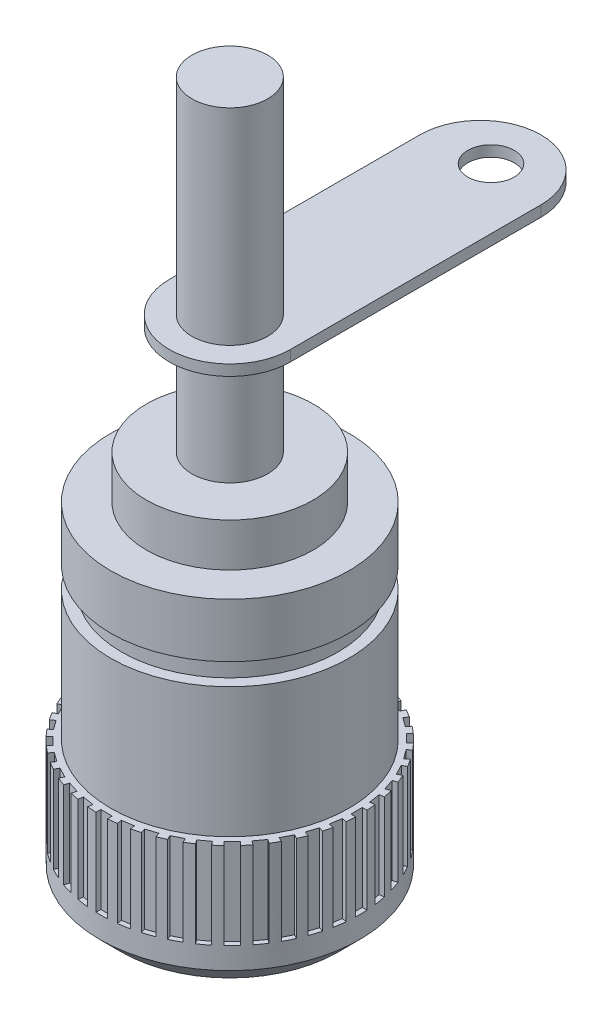
from build123d import *

# Parameters (mm, degrees)
SKETCH1_R           = 6
BOSS_EXTRUDE1_DEPTH = 12
SKETCH2_R           = 8.118200381
SKETCH2_R_2         = 5.5
CUT_EXTRUDE1_DEPTH  = 6
CHAMFER1_SIZE       = 1
SKETCH3_R           = 3.25
CUT_EXTRUDE2_DEPTH  = 6
SKETCH5_R           = 5
BOSS_EXTRUDE2_DEPTH = 1
SKETCH6_R           = 5.5
BOSS_EXTRUDE3_DEPTH = 2.5
SKETCH7_R           = 2.716529656
SKETCH7_R_2         = 2.485668045
BOSS_EXTRUDE4_DEPTH = 4.5
SKETCH8_R           = 3.85
BOSS_EXTRUDE5_DEPTH = 2
SKETCH9_R           = 1.75
BOSS_EXTRUDE6_DEPTH = 15
BOSS_EXTRUDE7_START = 5
BOSS_EXTRUDE7_DEPTH = 0.5
SKETCH11_R          = 1.071169835
CUT_EXTRUDE3_DEPTH  = 0.5
CUT_EXTRUDE4_START  = -2
SKETCH12_W          = 0.527806269
SKETCH12_H          = 0.650551913
SKETCH12_W_2        = 0.650551913
SKETCH12_H_2        = 0.527806269
CUT_EXTRUDE4_DEPTH  = 8.5


with BuildPart() as part:
    # Sketch1 → Boss-Extrude1 (new body)
    with BuildSketch(Plane(origin=(0, 0, 0), x_dir=(1, 0, 0), z_dir=(0, 1, 0))):
        Circle(SKETCH1_R)
    extrude(amount=BOSS_EXTRUDE1_DEPTH)

    # Sketch2 → Cut-Extrude1 (cut)
    with BuildSketch(Plane(origin=(0, 12, 0), x_dir=(1, 0, 0), z_dir=(0, 1, 0))):
        Circle(SKETCH2_R)
        Circle(SKETCH2_R_2, mode=Mode.SUBTRACT)
    extrude(amount=-CUT_EXTRUDE1_DEPTH, mode=Mode.SUBTRACT)

    # Chamfer1
    chamfer1_edges = [part.edges().sort_by_distance(p)[0] for p in [
        (-6, 0, 0),
    ]]
    chamfer(chamfer1_edges, length=CHAMFER1_SIZE)

    # Sketch3 → Cut-Extrude2 (cut)
    with BuildSketch(Plane.XZ):
        Circle(SKETCH3_R)
    extrude(amount=-CUT_EXTRUDE2_DEPTH, mode=Mode.SUBTRACT)

    # Sketch5 → Boss-Extrude2 (add)
    with BuildSketch(Plane(origin=(0, 12, 0), x_dir=(1, 0, 0), z_dir=(0, 1, 0))):
        Circle(SKETCH5_R)
    extrude(amount=BOSS_EXTRUDE2_DEPTH)

    # Sketch6 → Boss-Extrude3 (add)
    with BuildSketch(Plane(origin=(0, 13, 0), x_dir=(1, 0, 0), z_dir=(0, 1, 0))):
        Circle(SKETCH6_R)
    extrude(amount=BOSS_EXTRUDE3_DEPTH)

    # Sketch7 → Boss-Extrude4 (add)
    with BuildSketch(Plane.XZ.offset(-6)):
        Circle(SKETCH7_R)
        Circle(SKETCH7_R_2, mode=Mode.SUBTRACT)
    extrude(amount=BOSS_EXTRUDE4_DEPTH)

    # Sketch8 → Boss-Extrude5 (add)
    with BuildSketch(Plane(origin=(0, 15.5, 0), x_dir=(1, 0, 0), z_dir=(0, 1, 0))):
        Circle(SKETCH8_R)
    extrude(amount=BOSS_EXTRUDE5_DEPTH)

    # Sketch9 → Boss-Extrude6 (add)
    with BuildSketch(Plane(origin=(0, 17.5, 0), x_dir=(1, 0, 0), z_dir=(0, 1, 0))):
        Circle(SKETCH9_R)
    extrude(amount=BOSS_EXTRUDE6_DEPTH)

    # Sketch10 → Boss-Extrude7 (add)
    with BuildSketch(Plane(origin=(0, 17.5, 0), x_dir=(1, 0, 0), z_dir=(0, 1, 0)).offset(BOSS_EXTRUDE7_START)):
        with BuildLine():
            Line((-2.797833614, 0), (-2.797833614, 11.571992089))
            ThreePointArc((-2.797833614, 11.571992089), (0, 14.369825702), (2.797833614, 11.571992089))
            Line((2.797833614, 11.571992089), (2.797833614, 0))
            ThreePointArc((2.797833614, 0), (0, -2.797833614), (-2.797833614, 0))
        make_face()
    extrude(amount=BOSS_EXTRUDE7_DEPTH)

    # Sketch11 → Cut-Extrude3 (cut)
    with BuildSketch(Plane.XZ.offset(-22.5)):
        with Locations((0, -12.0617981)):
            Circle(SKETCH11_R)
    extrude(amount=-CUT_EXTRUDE3_DEPTH, mode=Mode.SUBTRACT)

    # Sketch12 → Cut-Extrude4 (cut)
    with BuildSketch(Plane.XZ.offset(CUT_EXTRUDE4_START)):
        Polygon((0.824722278, 6.374190464), (0.722953537, 5.731647924), (1.244261635, 5.649080833), (1.346030376, 6.291623372), align=None)
        with Locations((0.081328638, 6.099452634)):
            Rectangle(SKETCH12_W, SKETCH12_H)
        Polygon((1.811711653, 6.166698614), (1.610680056, 5.547986977), (2.112653648, 5.38488587), (2.313685245, 6.003597507), align=None)
        Polygon((2.754090675, 5.807362177), (2.458746287, 5.227716178), (2.929025116, 4.988097146), (3.224369505, 5.567743145), align=None)
        Polygon((3.628654844, 5.305029211), (3.246270024, 4.778721657), (3.673274265, 4.468484916), (4.055659086, 4.994792469), align=None)
        Polygon((4.413869488, 4.672068819), (3.953859819, 4.212059149), (4.327075211, 3.838843757), (4.78708488, 4.298853426), align=None)
        Polygon((5.090400017, 3.924066586), (4.564092463, 3.541681766), (4.874329204, 3.114677524), (5.400636758, 3.497062345), align=None)
        Polygon((5.641588003, 3.079440812), (5.061942003, 2.784096423), (5.301561035, 2.313817594), (5.881207035, 2.609161982), align=None)
        Polygon((6.053861369, 2.158988984), (5.435149732, 1.957957387), (5.598250839, 1.455983795), (6.216962476, 1.657015392), align=None)
        Polygon((6.317068576, 1.185375682), (5.674526036, 1.083606942), (5.757093128, 0.562298843), (6.399635668, 0.664067584), align=None)
        with Locations((6.099452634, -0.081328638)):
            Rectangle(SKETCH12_W_2, SKETCH12_H_2)
        Polygon((6.374190464, -0.824722278), (5.731647924, -0.722953537), (5.649080833, -1.244261635), (6.291623372, -1.346030376), align=None)
        Polygon((6.166698614, -1.811711653), (5.547986977, -1.610680056), (5.38488587, -2.112653648), (6.003597507, -2.313685245), align=None)
        Polygon((5.807362177, -2.754090675), (5.227716178, -2.458746287), (4.988097146, -2.929025116), (5.567743145, -3.224369505), align=None)
        Polygon((5.305029211, -3.628654844), (4.778721657, -3.246270024), (4.468484916, -3.673274265), (4.994792469, -4.055659086), align=None)
        Polygon((4.672068819, -4.413869488), (4.212059149, -3.953859819), (3.838843757, -4.327075211), (4.298853426, -4.78708488), align=None)
        Polygon((3.924066586, -5.090400017), (3.541681766, -4.564092463), (3.114677524, -4.874329204), (3.497062345, -5.400636758), align=None)
        Polygon((3.079440812, -5.641588003), (2.784096423, -5.061942003), (2.313817594, -5.301561035), (2.609161982, -5.881207035), align=None)
        Polygon((2.158988984, -6.053861369), (1.957957387, -5.435149732), (1.455983795, -5.598250839), (1.657015392, -6.216962476), align=None)
        Polygon((1.185375682, -6.317068576), (1.083606942, -5.674526036), (0.562298843, -5.757093128), (0.664067584, -6.399635668), align=None)
        with Locations((-0.081328638, -6.099452634)):
            Rectangle(SKETCH12_W, SKETCH12_H)
        Polygon((-0.824722278, -6.374190464), (-0.722953537, -5.731647924), (-1.244261635, -5.649080833), (-1.346030376, -6.291623372), align=None)
        Polygon((-1.811711653, -6.166698614), (-1.610680056, -5.547986977), (-2.112653648, -5.38488587), (-2.313685245, -6.003597507), align=None)
        Polygon((-2.754090675, -5.807362177), (-2.458746287, -5.227716178), (-2.929025116, -4.988097146), (-3.224369505, -5.567743145), align=None)
        Polygon((-3.628654844, -5.305029211), (-3.246270024, -4.778721657), (-3.673274265, -4.468484916), (-4.055659086, -4.994792469), align=None)
        Polygon((-4.413869488, -4.672068819), (-3.953859819, -4.212059149), (-4.327075211, -3.838843757), (-4.78708488, -4.298853426), align=None)
        Polygon((-5.090400017, -3.924066586), (-4.564092463, -3.541681766), (-4.874329204, -3.114677524), (-5.400636758, -3.497062345), align=None)
        Polygon((-5.641588003, -3.079440812), (-5.061942003, -2.784096423), (-5.301561035, -2.313817594), (-5.881207035, -2.609161982), align=None)
        Polygon((-6.053861369, -2.158988984), (-5.435149732, -1.957957387), (-5.598250839, -1.455983795), (-6.216962476, -1.657015392), align=None)
        Polygon((-6.317068576, -1.185375682), (-5.674526036, -1.083606942), (-5.757093128, -0.562298843), (-6.399635668, -0.664067584), align=None)
        with Locations((-6.099452634, 0.081328638)):
            Rectangle(SKETCH12_W_2, SKETCH12_H_2)
        Polygon((-6.374190464, 0.824722278), (-5.731647924, 0.722953537), (-5.649080833, 1.244261635), (-6.291623372, 1.346030376), align=None)
        Polygon((-6.166698614, 1.811711653), (-5.547986977, 1.610680056), (-5.38488587, 2.112653648), (-6.003597507, 2.313685245), align=None)
        Polygon((-5.807362177, 2.754090675), (-5.227716178, 2.458746287), (-4.988097146, 2.929025116), (-5.567743145, 3.224369505), align=None)
        Polygon((-5.305029211, 3.628654844), (-4.778721657, 3.246270024), (-4.468484916, 3.673274265), (-4.994792469, 4.055659086), align=None)
        Polygon((-4.672068819, 4.413869488), (-4.212059149, 3.953859819), (-3.838843757, 4.327075211), (-4.298853426, 4.78708488), align=None)
        Polygon((-3.924066586, 5.090400017), (-3.541681766, 4.564092463), (-3.114677524, 4.874329204), (-3.497062345, 5.400636758), align=None)
        Polygon((-3.079440812, 5.641588003), (-2.784096423, 5.061942003), (-2.313817594, 5.301561035), (-2.609161982, 5.881207035), align=None)
        Polygon((-2.158988984, 6.053861369), (-1.957957387, 5.435149732), (-1.455983795, 5.598250839), (-1.657015392, 6.216962476), align=None)
        Polygon((-1.185375682, 6.317068576), (-1.083606942, 5.674526036), (-0.562298843, 5.757093128), (-0.664067584, 6.399635668), align=None)
    extrude(amount=-CUT_EXTRUDE4_DEPTH, mode=Mode.SUBTRACT)


solid = part.part
